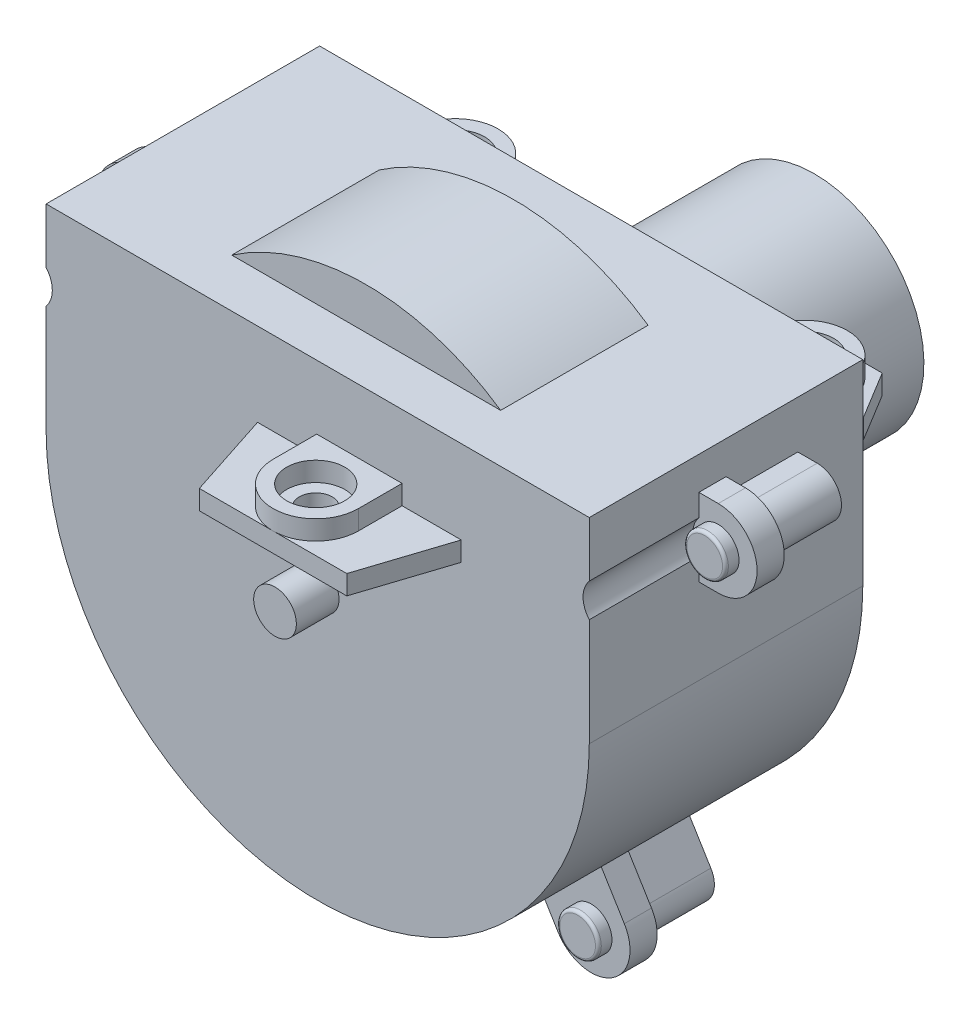
from build123d import *

# Parameters (mm, degrees)
BOSS_EXTRUDE1_DEPTH     = 17.907
SKETCH3_W               = 62.23
SKETCH3_H               = 19.304
BOSS_EXTRUDE3_DEPTH     = 19.05
CUT_EXTRUDE2_DEPTH      = 60.863359954
CUT_EXTRUDE2_DEPTH_BACK = 60.863359954
SKETCH7_R               = 14.351
BOSS_EXTRUDE5_DEPTH     = 29.21
SKETCH8_R               = 20.574
BOSS_EXTRUDE6_DEPTH     = 1.778
SKETCH9_R               = 2.794
BOSS_EXTRUDE7_DEPTH     = 5.588
SKETCH10_W              = 26.67
SKETCH10_H              = 2.54
BOSS_EXTRUDE8_DEPTH     = 11.303
CUT_EXTRUDE3_DEPTH      = 78.548762421
REVOLVE1_ANGLE          = 30
BOSS_EXTRUDE11_DEPTH    = 2.54
SKETCH19_R              = 3.81
CUT_EXTRUDE4_DEPTH      = 2.54
SKETCH20_R              = 2.159
CUT_EXTRUDE5_DEPTH      = 78.548762421
SKETCH21_W              = 24.638
SKETCH21_H              = 2.54
BOSS_EXTRUDE12_DEPTH    = 10.668
CUT_EXTRUDE6_DEPTH      = 78.548762421
BOSS_EXTRUDE13_DEPTH    = 2.54
SKETCH26_R              = 3.81
CUT_EXTRUDE7_DEPTH      = 2.54
SKETCH28_R              = 2.159
CUT_EXTRUDE8_DEPTH      = 104.988913405
BOSS_EXTRUDE14_DEPTH    = 2.54
SKETCH32_R              = 3.81
CUT_EXTRUDE9_DEPTH      = 2.54
SKETCH34_R              = 2.159
CUT_EXTRUDE10_DEPTH     = 117.535407804
SKETCH35_W              = 1.27
SKETCH35_H              = 2.8956
BOSS_EXTRUDE15_DEPTH    = 2.54
BOSS_EXTRUDE16_DEPTH    = 3.556
BOSS_EXTRUDE17_DEPTH    = 9.398
BOSS_EXTRUDE20_START    = 3.556
BOSS_EXTRUDE20_DEPTH    = 3.556
BOSS_EXTRUDE21_DEPTH    = 9.398
SKETCH46_R              = 3.3528
CUT_EXTRUDE11_DEPTH     = 14.732
SKETCH47_R              = 2.7178
BOSS_EXTRUDE22_DEPTH    = 1.778
SKETCH48_R              = 2.7178
BOSS_EXTRUDE23_DEPTH    = 1.778
SKETCH49_R              = 2.7178
BOSS_EXTRUDE24_DEPTH    = 1.778
FILLET2_R               = 0.381


with BuildPart() as part:
    # Sketch1 → Boss-Extrude1 (new, symmetric)
    with BuildSketch(Plane.XY):
        with BuildLine():
            Line((-35.56, 0), (-35.56, 25.654))
            Line((-35.56, 25.654), (35.56, 25.654))
            Line((35.56, 25.654), (35.56, 0))
            ThreePointArc((35.56, 0), (0, -35.56), (-35.56, 0))
        make_face()
    extrude(amount=BOSS_EXTRUDE1_DEPTH, both=True)

    # Sketch3 → Boss-Extrude3 (add)
    with BuildSketch(Plane(origin=(0, 25.654, 0), x_dir=(1, 0, 0), z_dir=(0, 1, 0))):
        with Locations((0, -1.905)):
            Rectangle(SKETCH3_W, SKETCH3_H)
    extrude(amount=BOSS_EXTRUDE3_DEPTH)

    # Sketch2 → Cut-Extrude2 (cut, two sides: drawn at the far end of the back side and taken through both)
    with BuildSketch(Plane.XY.offset(-CUT_EXTRUDE2_DEPTH_BACK)):
        with BuildLine():
            Line((17.607257282, 25.654), (31.115, 25.654))
            Line((31.115, 25.654), (31.115, 44.704))
            Line((31.115, 44.704), (-31.115, 44.704))
            Line((-31.115, 44.704), (-31.115, 25.654))
            Line((-31.115, 25.654), (-17.607257282, 25.654))
            ThreePointArc((-17.607257282, 25.654), (0, 31.115), (17.607257282, 25.654))
        make_face()
    extrude(amount=CUT_EXTRUDE2_DEPTH + CUT_EXTRUDE2_DEPTH_BACK, mode=Mode.SUBTRACT)

    # Sketch7 → Boss-Extrude5 (add)
    with BuildSketch(Plane(origin=(0, 0, -17.907), x_dir=(-1, 0, 0), z_dir=(0, 0, -1))):
        Circle(SKETCH7_R)
    extrude(amount=BOSS_EXTRUDE5_DEPTH)

    # Sketch8 → Boss-Extrude6 (add)
    with BuildSketch(Plane(origin=(0, 0, -17.907), x_dir=(-1, 0, 0), z_dir=(0, 0, -1))):
        Circle(SKETCH8_R)
    extrude(amount=BOSS_EXTRUDE6_DEPTH)

    # Sketch9 → Boss-Extrude7 (add)
    with BuildSketch(Plane.XY.offset(17.907)):
        Circle(SKETCH9_R)
    extrude(amount=BOSS_EXTRUDE7_DEPTH)

    # Sketch10 → Boss-Extrude8 (add)
    with BuildSketch(Plane.XY.offset(17.907)):
        with Locations((5.461, 13.462)):
            Rectangle(SKETCH10_W, SKETCH10_H)
    extrude(amount=BOSS_EXTRUDE8_DEPTH)

    # Sketch11 → Cut-Extrude3 (cut, through all)
    with BuildSketch(Plane(origin=(0, 14.732, 0), x_dir=(1, 0, 0), z_dir=(0, 1, 0))):
        Polygon((-7.874, -17.907), (-4.191, -29.21), (-7.874, -29.21), align=None)
        Polygon((18.796, -17.907), (15.113, -29.21), (18.796, -29.21), align=None)
    extrude(amount=-CUT_EXTRUDE3_DEPTH, mode=Mode.SUBTRACT)

    # Sketch15 → Revolve1 (revolve, symmetric)
    with BuildSketch(Plane(origin=(0, 0, 0), x_dir=(-1, 0, 0), z_dir=(0, 1, 0))) as revolve1_sk:
        Polygon((-14.351, -26.289), (-14.351, -19.685), (-20.574, -19.685), align=None)
    revolve1 = revolve(axis=Axis((0, 0, -47.117), (0, 0, 1)), revolution_arc=REVOLVE1_ANGLE / 2)
    revolve1 = revolve1 + revolve(revolve1_sk.sketch, axis=Axis((0, 0, -47.117), (0, 0, -1)), revolution_arc=REVOLVE1_ANGLE / 2)

    # Mirror4: Revolve1 across plane
    add(revolve1.mirror(Plane(origin=(0, 0, 0), x_dir=(0, 0, 1), z_dir=(1, 0, 0))))

    # Sketch16 → Boss-Extrude11 (add)
    with BuildSketch(Plane(origin=(0, 14.732, 0), x_dir=(1, 0, 0), z_dir=(0, 1, 0))):
        with BuildLine():
            Line((-0.127, -17.907), (-0.127, -23.622))
            ThreePointArc((-0.127, -23.622), (5.461, -29.21), (11.049, -23.622))
            Line((11.049, -23.622), (11.049, -17.907))
            Line((11.049, -17.907), (-0.127, -17.907))
        make_face()
    extrude(amount=BOSS_EXTRUDE11_DEPTH)

    # Sketch19 → Cut-Extrude4 (cut)
    with BuildSketch(Plane(origin=(0, 17.272, 0), x_dir=(1, 0, 0), z_dir=(0, 1, 0))):
        with Locations((5.461, -23.622)):
            Circle(SKETCH19_R)
    extrude(amount=-CUT_EXTRUDE4_DEPTH, mode=Mode.SUBTRACT)

    # Sketch20 → Cut-Extrude5 (cut, through all)
    with BuildSketch(Plane(origin=(0, 14.732, 0), x_dir=(1, 0, 0), z_dir=(0, 1, 0))):
        with Locations((5.461, -23.622)):
            Circle(SKETCH20_R)
    extrude(amount=-CUT_EXTRUDE5_DEPTH, mode=Mode.SUBTRACT)

    # Sketch21 → Boss-Extrude12 (add)
    with BuildSketch(Plane(origin=(0, 0, -17.907), x_dir=(-1, 0, 0), z_dir=(0, 0, -1))):
        with Locations((-18.923, 13.462)):
            Rectangle(SKETCH21_W, SKETCH21_H)
    boss_extrude12 = extrude(amount=BOSS_EXTRUDE12_DEPTH)

    # Sketch22 → Cut-Extrude6 (cut, through all)
    with BuildSketch(Plane(origin=(0, 14.732, 0), x_dir=(1, 0, 0), z_dir=(0, 1, 0))):
        Polygon((31.242, 22.3012), (27.432, 28.575), (31.242, 28.575), align=None)
    cut_extrude6 = extrude(amount=-CUT_EXTRUDE6_DEPTH, mode=Mode.SUBTRACT)

    # Sketch24 → Boss-Extrude13 (add)
    with BuildSketch(Plane(origin=(10.777761336, 14.732, -49.130415633), x_dir=(1, 0, 0), z_dir=(0, 1, 0))):
        with BuildLine():
            Line((6.494238664, -31.223415633), (6.494238664, -26.143415633))
            ThreePointArc((6.494238664, -26.143415633), (12.082238664, -20.555415633), (17.670238664, -26.143415633))
            Line((17.670238664, -26.143415633), (17.670238664, -31.223415633))
            Line((17.670238664, -31.223415633), (6.494238664, -31.223415633))
        make_face()
    extrude(amount=BOSS_EXTRUDE13_DEPTH)

    # Sketch26 → Cut-Extrude7 (cut)
    with BuildSketch(Plane(origin=(10.777761336, 17.272, -49.130415633), x_dir=(1, 0, 0), z_dir=(0, 1, 0))):
        with Locations((12.082238664, -26.143415633)):
            Circle(SKETCH26_R)
    extrude(amount=-CUT_EXTRUDE7_DEPTH, mode=Mode.SUBTRACT)

    # Sketch28 → Cut-Extrude8 (cut, through all)
    with BuildSketch(Plane(origin=(10.777761336, 14.732, -49.130415633), x_dir=(1, 0, 0), z_dir=(0, 1, 0))):
        with Locations((12.082238664, -26.143415633)):
            Circle(SKETCH28_R)
    extrude(amount=-CUT_EXTRUDE8_DEPTH, mode=Mode.SUBTRACT)

    # Mirror5: Boss-Extrude12, Cut-Extrude6 across plane
    add(boss_extrude12.mirror(Plane(origin=(0, 0, 0), x_dir=(0, 0, 1), z_dir=(1, 0, 0))))
    add(cut_extrude6.mirror(Plane(origin=(0, 0, 0), x_dir=(0, 0, 1), z_dir=(1, 0, 0))), mode=Mode.SUBTRACT)

    # Sketch30 → Boss-Extrude14 (add)
    with BuildSketch(Plane(origin=(-34.117661683, 14.732, -49.506195732), x_dir=(1, 0, 0), z_dir=(0, 1, 0))):
        with BuildLine():
            Line((5.669661683, -31.599195732), (5.669661683, -26.519195732))
            ThreePointArc((5.669661683, -26.519195732), (11.257661683, -20.931195732), (16.845661683, -26.519195732))
            Line((16.845661683, -26.519195732), (16.845661683, -31.599195732))
            Line((16.845661683, -31.599195732), (5.669661683, -31.599195732))
        make_face()
    extrude(amount=BOSS_EXTRUDE14_DEPTH)

    # Sketch32 → Cut-Extrude9 (cut)
    with BuildSketch(Plane(origin=(-34.117661683, 17.272, -49.506195732), x_dir=(1, 0, 0), z_dir=(0, 1, 0))):
        with Locations((11.257661683, -26.519195732)):
            Circle(SKETCH32_R)
    extrude(amount=-CUT_EXTRUDE9_DEPTH, mode=Mode.SUBTRACT)

    # Sketch34 → Cut-Extrude10 (cut, through all)
    with BuildSketch(Plane(origin=(-34.117661683, 14.732, -49.506195732), x_dir=(1, 0, 0), z_dir=(0, 1, 0))):
        with Locations((11.257661683, -26.519195732)):
            Circle(SKETCH34_R)
    extrude(amount=-CUT_EXTRUDE10_DEPTH, mode=Mode.SUBTRACT)

    # Sketch35 → Boss-Extrude15 (add)
    with BuildSketch(Plane(origin=(0, 0, -47.117), x_dir=(-1, 0, 0), z_dir=(0, 0, -1))):
        with Locations((-10.16, 0)):
            Rectangle(SKETCH35_W, SKETCH35_H)
    boss_extrude15 = extrude(amount=BOSS_EXTRUDE15_DEPTH)

    # Mirror6: Boss-Extrude15 across plane
    add(boss_extrude15.mirror(Plane(origin=(0, 0, 0), x_dir=(0, 0, 1), z_dir=(1, 0, 0))))

    # Sketch37 → Boss-Extrude16 (add)
    with BuildSketch(Plane.XY):
        with BuildLine():
            Line((38.1, 21.336), (35.56, 21.336))
            Line((35.56, 21.336), (35.56, 11.176))
            Line((35.56, 11.176), (38.1, 11.176))
            ThreePointArc((38.1, 11.176), (43.18, 16.256), (38.1, 21.336))
        make_face()
        with BuildLine():
            Line((-38.1, 21.336), (-35.56, 21.336))
            Line((-35.56, 21.336), (-35.56, 11.176))
            Line((-35.56, 11.176), (-38.1, 11.176))
            ThreePointArc((-38.1, 11.176), (-43.18, 16.256), (-38.1, 21.336))
        make_face()
    extrude(amount=BOSS_EXTRUDE16_DEPTH)

    # Sketch38 → Boss-Extrude17 (add)
    with BuildSketch(Plane(origin=(0, 0, 0), x_dir=(-1, 0, 0), z_dir=(0, 0, -1))):
        with BuildLine():
            Line((-35.56, 13.081), (-35.56, 19.431))
            Line((-35.56, 19.431), (-38.1, 19.431))
            ThreePointArc((-38.1, 19.431), (-41.275, 16.256), (-38.1, 13.081))
            Line((-38.1, 13.081), (-35.56, 13.081))
        make_face()
    boss_extrude17 = extrude(amount=BOSS_EXTRUDE17_DEPTH)

    # Mirror7: Boss-Extrude17 across plane
    add(boss_extrude17.mirror(Plane(origin=(0, 0, 0), x_dir=(0, 0, 1), z_dir=(1, 0, 0))))

    # Sketch43 → Boss-Extrude20 (add)
    with BuildSketch(Plane.XY.offset(BOSS_EXTRUDE20_START)):
        with BuildLine():
            Line((-22.692218542, -27.378400568), (-25.797190649, -32.45719117))
            ThreePointArc((-25.797190649, -32.45719117), (-24.112753086, -39.441134905), (-17.128809351, -37.756697343))
            Line((-17.128809351, -37.756697343), (-14.023837244, -32.677906741))
            ThreePointArc((-14.023837244, -32.677906741), (-18.548271605, -30.339334542), (-22.692218542, -27.378400568))
        make_face()
        with BuildLine():
            Line((22.692218542, -27.378400568), (25.797190649, -32.45719117))
            ThreePointArc((25.797190649, -32.45719117), (24.112753086, -39.441134905), (17.128809351, -37.756697343))
            Line((17.128809351, -37.756697343), (14.023837244, -32.677906741))
            ThreePointArc((14.023837244, -32.677906741), (18.548271605, -30.339334542), (22.692218542, -27.378400568))
        make_face()
    extrude(amount=-BOSS_EXTRUDE20_DEPTH)

    # Sketch45 → Boss-Extrude21 (add)
    with BuildSketch(Plane.XY):
        with BuildLine():
            Line((21.18305998, -28.562065224), (24.171869156, -33.450848577))
            ThreePointArc((24.171869156, -33.450848577), (23.119095679, -37.815813412), (18.754130844, -36.763039935))
            Line((18.754130844, -36.763039935), (15.765321669, -31.874256582))
            ThreePointArc((15.765321669, -31.874256582), (18.548271605, -30.339334542), (21.18305998, -28.562065224))
        make_face()
        with BuildLine():
            Line((-15.765321669, -31.874256582), (-18.754130844, -36.763039935))
            ThreePointArc((-18.754130844, -36.763039935), (-23.119095679, -37.815813412), (-24.171869156, -33.450848577))
            Line((-24.171869156, -33.450848577), (-21.18305998, -28.562065224))
            ThreePointArc((-21.18305998, -28.562065224), (-18.548271605, -30.339334542), (-15.765321669, -31.874256582))
        make_face()
    extrude(amount=-BOSS_EXTRUDE21_DEPTH)

    # Sketch46 → Cut-Extrude11 (cut)
    with BuildSketch(Plane.XY.offset(3.556)):
        with Locations((-38.1, 16.256)):
            Circle(SKETCH46_R)
    cut_extrude11 = extrude(amount=CUT_EXTRUDE11_DEPTH, mode=Mode.SUBTRACT)

    # Mirror8: Cut-Extrude11 across plane
    add(cut_extrude11.mirror(Plane(origin=(0, 0, 0), x_dir=(0, 0, 1), z_dir=(1, 0, 0))), mode=Mode.SUBTRACT)

    # Sketch47 → Boss-Extrude22 (add)
    with BuildSketch(Plane.XY.offset(3.556)):
        with Locations((-38.1, 16.256)):
            Circle(SKETCH47_R)
    boss_extrude22 = extrude(amount=BOSS_EXTRUDE22_DEPTH)

    # Mirror9: Boss-Extrude22 across plane
    add(boss_extrude22.mirror(Plane(origin=(0, 0, 0), x_dir=(0, 0, 1), z_dir=(1, 0, 0))))

    # Sketch48 → Boss-Extrude23 (add)
    with BuildSketch(Plane.XY.offset(3.556)):
        with Locations((-21.463, -35.106944256)):
            Circle(SKETCH48_R)
    extrude(amount=BOSS_EXTRUDE23_DEPTH)

    # Sketch49 → Boss-Extrude24 (add)
    with BuildSketch(Plane.XY.offset(3.556)):
        with Locations((21.463, -35.106944256)):
            Circle(SKETCH49_R)
    extrude(amount=BOSS_EXTRUDE24_DEPTH)

    # Fillet2
    fillet2_edges = [part.edges().sort_by_distance(p)[0] for p in [
        (40.8178, 16.256, 5.334),
        (18.7452, -35.106944256, 5.334),
        (-40.8178, 16.256, 5.334),
        (-24.1808, -35.106944256, 5.334),
    ]]
    fillet(fillet2_edges, radius=FILLET2_R)


solid = part.part
